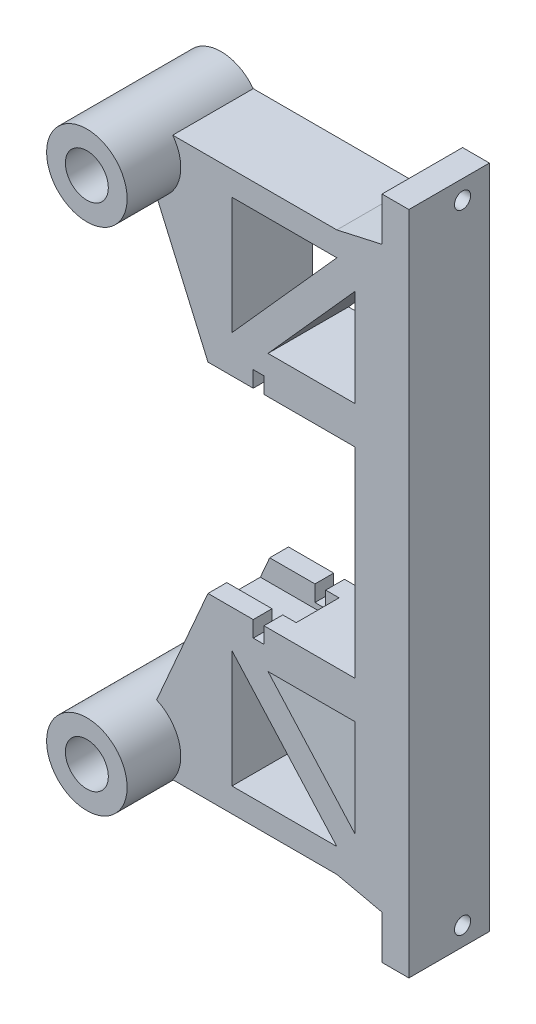
from build123d import *

# Parameters (mm, degrees)
CROQUIS1_R                 = 4
SALIENTE_EXTRUIR2_DEPTH    = 15
CROQUIS2_R                 = 7.5
CROQUIS2_R_2               = 4
SALIENTE_EXTRUIR3_DEPTH    = 10
CROQUIS3_R                 = 4.006471319
CROQUIS3_R_2               = 4.004031771
SALIENTE_EXTRUIR4_DEPTH    = 2
CROQUIS4_R                 = 1.5
CORTAR_EXTRUIR1_DEPTH      = 6
CROQUIS5_W                 = 8
CROQUIS5_H                 = 4
CORTAR_EXTRUIR2_DEPTH      = 15
CORTAR_EXTRUIR2_DEPTH_BACK = 2.5


with BuildPart() as part:
    # Croquis1 → Saliente-Extruir2 (new body)
    with BuildSketch(Plane.XY):
        with BuildLine():
            Line((28.5, 85.161764706), (28.5, 47.838235294))
            Line((28.5, 47.838235294), (11.5, 47.838235294))
            Line((11.5, 47.838235294), (11.5, 44.838235294))
            Line((11.5, 44.838235294), (9.5, 44.838235294))
            Line((9.5, 44.838235294), (9.5, 47.838235294))
            Line((9.5, 47.838235294), (1.067079587, 47.838235294))
            Line((1.067079587, 47.838235294), (-8.503797206, 25.875519531))
            ThreePointArc((-8.503797206, 25.875519531), (-18.751450015, 17.08519644), (-5.5, 14.5))
            Line((-5.5, 14.5), (25.080237482, 14.5))
            Line((25.080237482, 14.5), (33.5, 12.617754504))
            Line((33.5, 12.617754504), (33.5, 4.5))
            Line((33.5, 4.5), (38.5, 4.5))
            Line((38.5, 4.5), (38.5, 11.5))
            Line((38.5, 11.5), (38.5, 121.5))
            Line((38.5, 121.5), (38.5, 128.5))
            Line((38.5, 128.5), (33.5, 128.5))
            Line((33.5, 128.5), (33.5, 120.382245496))
            Line((33.5, 120.382245496), (25.080237482, 118.5))
            Line((25.080237482, 118.5), (-5.5, 118.5))
            ThreePointArc((-5.5, 118.5), (-18.751450015, 115.91480356), (-8.503797206, 107.124480469))
            Line((-8.503797206, 107.124480469), (1.067079587, 85.161764706))
            Line((1.067079587, 85.161764706), (9.5, 85.161764706))
            Line((9.5, 85.161764706), (9.5, 88.161764706))
            Line((9.5, 88.161764706), (11.5, 88.161764706))
            Line((11.5, 88.161764706), (11.5, 85.161764706))
            Line((11.5, 85.161764706), (28.5, 85.161764706))
        make_face()
        with Locations((-11.5, 114)):
            Circle(CROQUIS1_R, mode=Mode.SUBTRACT)
        with Locations((-11.5, 19)):
            Circle(CROQUIS1_R, mode=Mode.SUBTRACT)
        Polygon((28.5, 22.676470588), (28.5, 40.838235294), (12.25, 40.838235294), align=None, mode=Mode.SUBTRACT)
        Polygon((28.5, 110.323529412), (28.5, 92.161764706), (12.25, 92.161764706), align=None, mode=Mode.SUBTRACT)
        Polygon((25.080237482, 114), (5.540763798, 92.161764706), (5.540763798, 114), align=None, mode=Mode.SUBTRACT)
        Polygon((5.540763798, 40.838235294), (25.080237482, 19), (5.540763798, 19), align=None, mode=Mode.SUBTRACT)
    extrude(amount=SALIENTE_EXTRUIR2_DEPTH)

    # Croquis2 → Saliente-Extruir3 (add)
    with BuildSketch(Plane.XY.offset(15)):
        with Locations((-11.5, 114)):
            Circle(CROQUIS2_R)
        with Locations((-11.5, 114)):
            Circle(CROQUIS2_R_2, mode=Mode.SUBTRACT)
        with Locations((-11.5, 19)):
            Circle(CROQUIS2_R)
        with Locations((-11.5, 19)):
            Circle(CROQUIS2_R_2, mode=Mode.SUBTRACT)
    extrude(amount=SALIENTE_EXTRUIR3_DEPTH)

    # Croquis3 → Saliente-Extruir4 (add)
    with BuildSketch(Plane(origin=(0, 0, 0), x_dir=(-1, 0, 0), z_dir=(0, 0, -1))):
        with Locations((11.5, 114)):
            Circle(CROQUIS3_R)
        with Locations((11.5, 19)):
            Circle(CROQUIS3_R_2)
    extrude(amount=-SALIENTE_EXTRUIR4_DEPTH)

    # Croquis4 → Cortar-Extruir1 (cut, through all)
    with BuildSketch(Plane.ZY.offset(-33.5)):
        with Locations((5, 125)):
            Circle(CROQUIS4_R)
        with Locations((5, 8)):
            Circle(CROQUIS4_R)
    extrude(amount=-CORTAR_EXTRUIR1_DEPTH, mode=Mode.SUBTRACT)

    # Croquis5 → Cortar-Extruir2 (cut, two sides)
    with BuildSketch(Plane.ZY.offset(-11.5)) as cortar_extruir2_sk:
        with Locations((7.5, 87.161764706)):
            Rectangle(CROQUIS5_W, CROQUIS5_H)
        with Locations((7.5, 45.838235294)):
            Rectangle(CROQUIS5_W, CROQUIS5_H)
    extrude(amount=CORTAR_EXTRUIR2_DEPTH, mode=Mode.SUBTRACT)
    extrude(cortar_extruir2_sk.sketch, amount=-CORTAR_EXTRUIR2_DEPTH_BACK, mode=Mode.SUBTRACT)


solid = part.part
